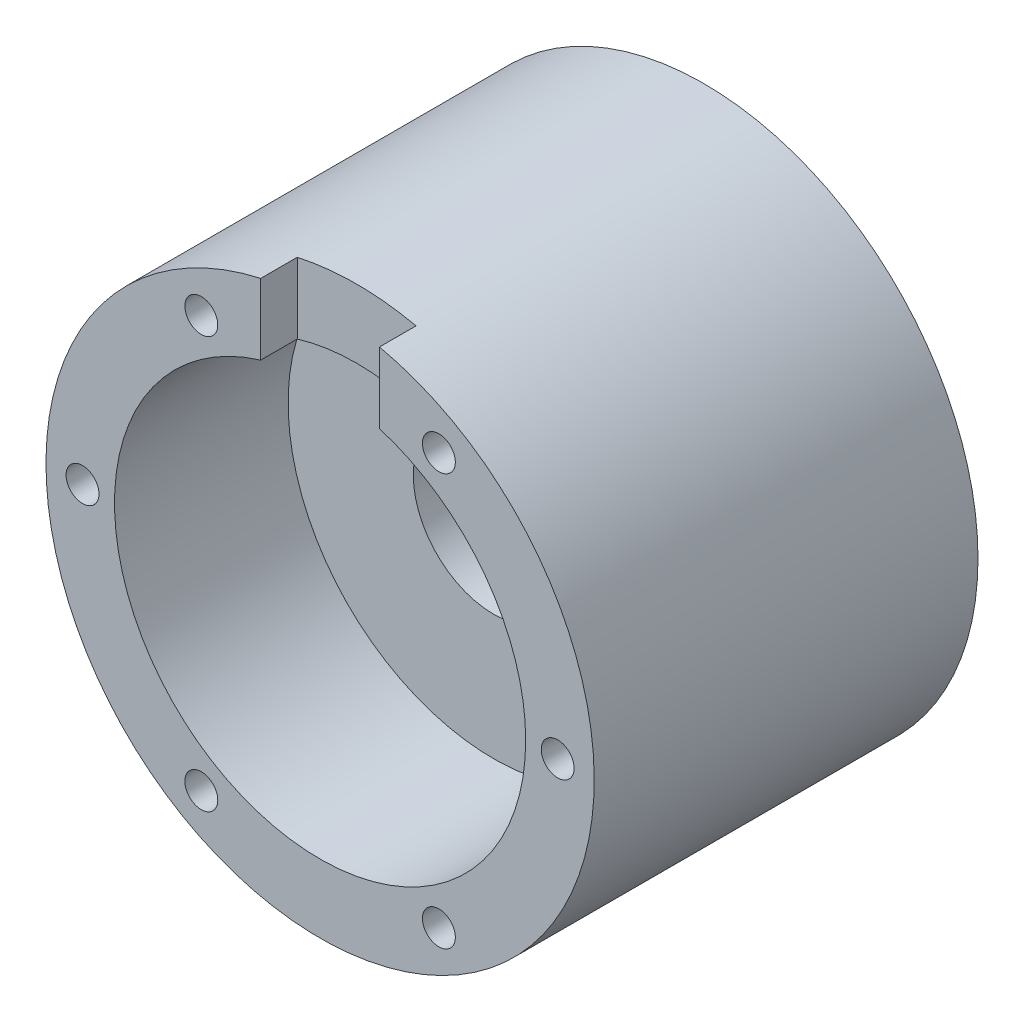
from build123d import *

# Parameters (mm, degrees)
SKETCH_1_R          = 15
SKETCH_1_R_2        = 4.4
SKETCH_1_R_3        = 1.45
EXTRUDE_1_DEPTH     = 21
SKETCH_2_R          = 7.7
CUT_EXTRUDE_1_DEPTH = 4
SKETCH_3_R          = 11.25
CUT_EXTRUDE_2_DEPTH = 9.5
SKETCH_4_R          = 0.9
CUT_EXTRUDE_3_DEPTH = 4
SKETCH_5_W          = 6.5
SKETCH_5_H          = 9
CUT_EXTRUDE_4_DEPTH = 2


with BuildPart() as part:
    # 스케치1 → 보스-돌출1 (new body)
    with BuildSketch(Plane.XY):
        Circle(SKETCH_1_R)
        Circle(SKETCH_1_R_2, mode=Mode.SUBTRACT)
        with Locations((0, 6.25)):
            Circle(SKETCH_1_R_3, mode=Mode.SUBTRACT)
    extrude(amount=EXTRUDE_1_DEPTH)

    # 스케치2 → 컷-돌출1 (cut)
    with BuildSketch(Plane(origin=(0, 0, 0), x_dir=(-1, 0, 0), z_dir=(0, 0, -1))):
        Circle(SKETCH_2_R)
    extrude(amount=-CUT_EXTRUDE_1_DEPTH, mode=Mode.SUBTRACT)

    # 스케치3 → 컷-돌출2 (cut)
    with BuildSketch(Plane.XY.offset(21)):
        Circle(SKETCH_3_R)
    extrude(amount=-CUT_EXTRUDE_2_DEPTH, mode=Mode.SUBTRACT)

    # 스케치4 → 컷-돌출3 (cut)
    with BuildSketch(Plane.XY.offset(21)):
        with Locations((13, 0)):
            Circle(SKETCH_4_R)
        with Locations((6.5, -11.258330249)):
            Circle(SKETCH_4_R)
        with Locations((-6.5, -11.258330249)):
            Circle(SKETCH_4_R)
        with Locations((-13, 0)):
            Circle(SKETCH_4_R)
        with Locations((-6.5, 11.258330249)):
            Circle(SKETCH_4_R)
        with Locations((6.5, 11.258330249)):
            Circle(SKETCH_4_R)
    extrude(amount=-CUT_EXTRUDE_3_DEPTH, mode=Mode.SUBTRACT)

    # 스케치5 → 컷-돌출4 (cut)
    with BuildSketch(Plane.XY.offset(21)):
        with Locations((0, 12)):
            Rectangle(SKETCH_5_W, SKETCH_5_H)
    extrude(amount=-CUT_EXTRUDE_4_DEPTH, mode=Mode.SUBTRACT)


solid = part.part
